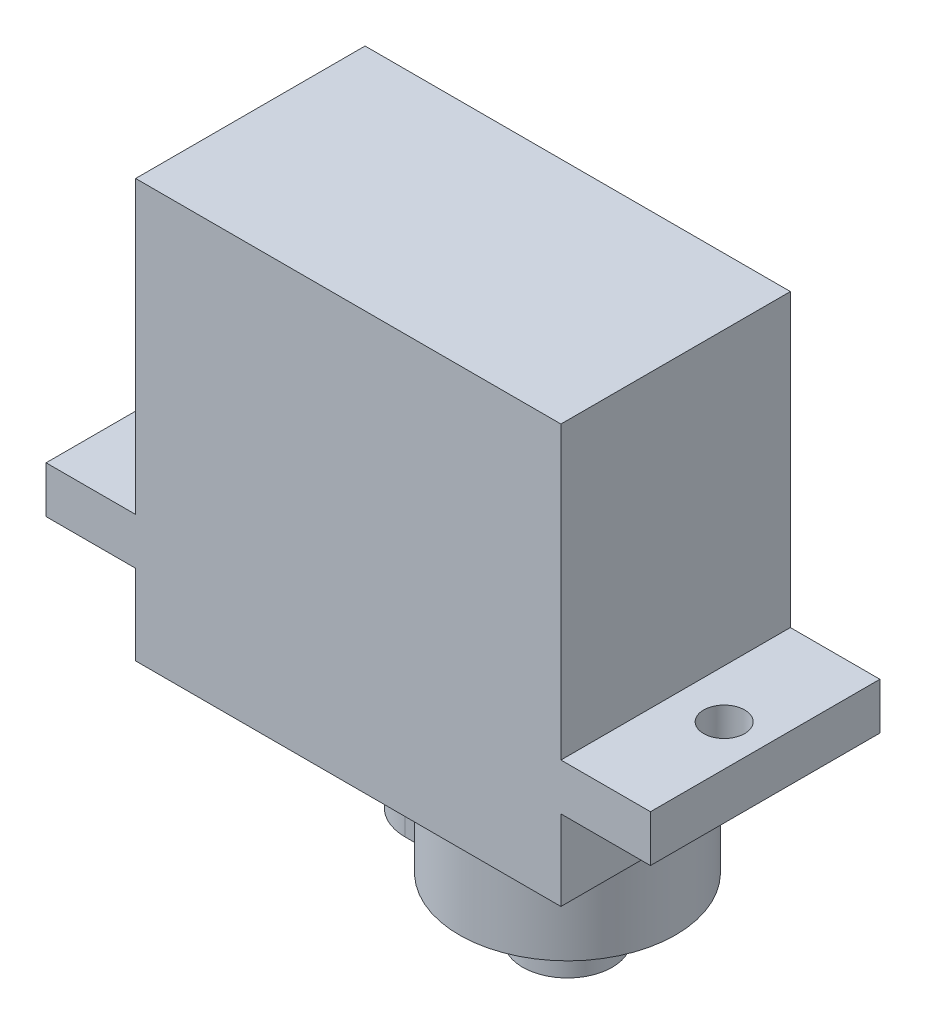
from build123d import *

# Parameters (mm, degrees)
BOSS_EXTRUDE1_DEPTH = 12.3
BOSS_EXTRUDE2_DEPTH = 4.4
SKETCH3_R           = 1.1
CUT_EXTRUDE1_DEPTH  = 8
SKETCH_1_R          = 2.4
EXTRUDE_1_DEPTH     = 3.2


with BuildPart() as part:
    # Sketch1 → Boss-Extrude1 (new body)
    with BuildSketch(Plane.XY):
        Polygon((-16.2, 0), (-11.4, 0), (-11.4, -4.3), (11.4, -4.3), (11.4, 0), (16.2, 0), (16.2, 2.5), (11.4, 2.5), (11.4, 18.1), (-11.4, 18.1), (-11.4, 2.5), (-16.2, 2.5), align=None)
    extrude(amount=BOSS_EXTRUDE1_DEPTH)

    # Sketch2 → Boss-Extrude2 (add)
    with BuildSketch(Plane.XZ.offset(4.3)):
        with BuildLine():
            Line((-0.4, 8.85), (0.466774893, 8.85))
            ThreePointArc((0.466774893, 8.85), (11.4, 6.15), (0.466774893, 3.45))
            Line((0.466774893, 3.45), (-0.4, 3.45))
            ThreePointArc((-0.4, 3.45), (-3.1, 6.15), (-0.4, 8.85))
        make_face()
    extrude(amount=BOSS_EXTRUDE2_DEPTH)

    # Sketch3 → Cut-Extrude1 (cut)
    with BuildSketch(Plane(origin=(0, 2.5, 0), x_dir=(1, 0, 0), z_dir=(0, 1, 0))):
        with Locations((-14, -6.15)):
            Circle(SKETCH3_R)
        with Locations((14, -6.15)):
            Circle(SKETCH3_R)
    extrude(amount=-CUT_EXTRUDE1_DEPTH, mode=Mode.SUBTRACT)


with BuildPart() as body_2:
    # 草圖1 → 填料-伸長1 (new body)
    with BuildSketch(Plane(origin=(0, -8.7, 0), x_dir=(-1, 0, 0), z_dir=(0, -1, 0))):
        with Locations((-5.6, -6.15)):
            Circle(SKETCH_1_R)
    extrude(amount=EXTRUDE_1_DEPTH)


solid = Compound([part.part, body_2.part])
